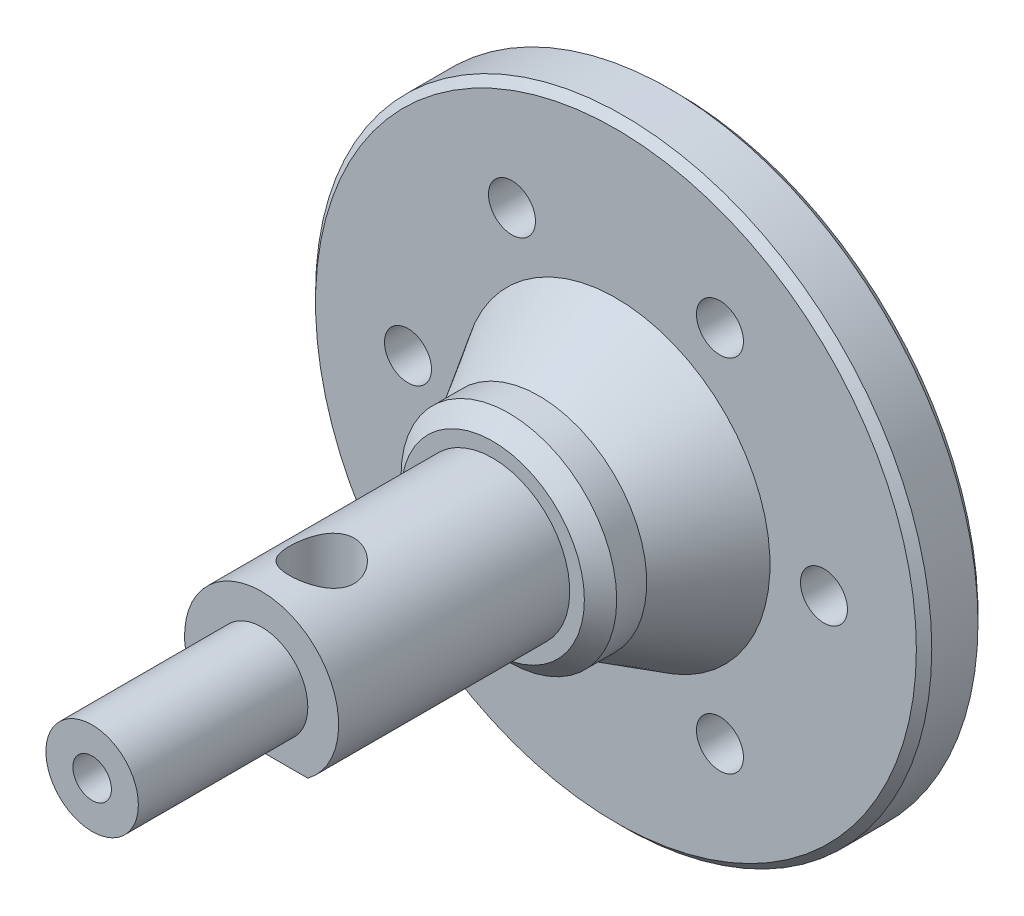
from build123d import *

# Parameters (mm, degrees)
SKETCH_1_R             = 20
EXTRUDE_1_DEPTH        = 5
SKETCH_2_R             = 1.525
CUT_EXTRUDE_1_DEPTH    = 5
SKETCH_3_R             = 7
EXTRUDE_2_DEPTH        = 4
SKETCH_4_R             = 5
EXTRUDE_3_DEPTH        = 15
CHAMFER_2_SIZE         = 1.05
CUT_EXTRUDE_2_DEPTH    = 15
SKETCH_7_R             = 3
EXTRUDE_4_DEPTH        = 10
SKETCH_8_R             = 20
SKETCH_8_R_2           = 7
CUT_EXTRUDE_3_DEPTH    = 1
SKETCH_9_R             = 20
SKETCH_9_R_2           = 1.525
EXTRUDE_5_DEPTH        = 3
SKETCH_10_R            = 20
SKETCH_10_R_2          = 7
CUT_EXTRUDE_4_DEPTH    = 3
SKETCH_11_R            = 3
EXTRUDE_6_DEPTH        = 1
HOLE_WIZARD_M3_1_D     = 2.5
HOLE_WIZARD_M3_1_DEPTH = 5
HOLE_WIZARD_M3_1_TIP   = 0.751075774
CHAMFER_3_SIZE         = 0.5
HOLE_WIZARD_M5_1_D     = 4.2
CHAMFER_4_SIZE         = 1


with BuildPart() as part:
    # 草图1 → 凸台-拉伸1 (new body)
    with BuildSketch(Plane.XY):
        Circle(SKETCH_1_R)
    extrude(amount=EXTRUDE_1_DEPTH)

    # 草图2 → 切除-拉伸1 (cut)
    with BuildSketch(Plane.XY.offset(5)):
        with Locations((13.5, 0)):
            Circle(SKETCH_2_R)
        with Locations((6.75, -11.691342951)):
            Circle(SKETCH_2_R)
        with Locations((-6.75, -11.691342951)):
            Circle(SKETCH_2_R)
        with Locations((-13.5, 0)):
            Circle(SKETCH_2_R)
        with Locations((-6.75, 11.691342951)):
            Circle(SKETCH_2_R)
        with Locations((6.75, 11.691342951)):
            Circle(SKETCH_2_R)
    extrude(amount=-CUT_EXTRUDE_1_DEPTH, mode=Mode.SUBTRACT)

    # 草图3 → 凸台-拉伸2 (add)
    with BuildSketch(Plane.XY.offset(5)):
        Circle(SKETCH_3_R)
    extrude(amount=EXTRUDE_2_DEPTH)

    # 草图4 → 凸台-拉伸3 (add)
    with BuildSketch(Plane.XY.offset(9)):
        Circle(SKETCH_4_R)
    extrude(amount=EXTRUDE_3_DEPTH)

    # 倒角2
    chamfer_2_edges = [part.edges().sort_by_distance(p)[0] for p in [
        (-7, 0, 9),
    ]]
    chamfer(chamfer_2_edges, length=CHAMFER_2_SIZE)

    # 草图6 → 切除-拉伸2 (cut)
    with BuildSketch(Plane.XY.offset(24)):
        with BuildLine():
            Line((-3, -4), (3, -4))
            ThreePointArc((3, -4), (0, -5), (-3, -4))
        make_face()
    extrude(amount=-CUT_EXTRUDE_2_DEPTH, mode=Mode.SUBTRACT)

    # 草图7 → 凸台-拉伸4 (add)
    with BuildSketch(Plane.XY.offset(24)):
        Circle(SKETCH_7_R)
    extrude(amount=EXTRUDE_4_DEPTH)

    # 草图8 → 切除-拉伸3 (cut)
    with BuildSketch(Plane.XY.offset(5)):
        Circle(SKETCH_8_R)
        Circle(SKETCH_8_R_2, mode=Mode.SUBTRACT)
    extrude(amount=-CUT_EXTRUDE_3_DEPTH, mode=Mode.SUBTRACT)

    # 草图9 → 凸台-拉伸5 (add)
    with BuildSketch(Plane(origin=(0, 0, 0), x_dir=(-1, 0, 0), z_dir=(0, 0, -1))):
        Circle(SKETCH_9_R)
        with Locations((6.75, 11.691342951)):
            Circle(SKETCH_9_R_2, mode=Mode.SUBTRACT)
        with Locations((13.5, 0)):
            Circle(SKETCH_9_R_2, mode=Mode.SUBTRACT)
        with Locations((6.75, -11.691342951)):
            Circle(SKETCH_9_R_2, mode=Mode.SUBTRACT)
        with Locations((-6.75, -11.691342951)):
            Circle(SKETCH_9_R_2, mode=Mode.SUBTRACT)
        with Locations((-13.5, 0)):
            Circle(SKETCH_9_R_2, mode=Mode.SUBTRACT)
        with Locations((-6.75, 11.691342951)):
            Circle(SKETCH_9_R_2, mode=Mode.SUBTRACT)
    extrude(amount=EXTRUDE_5_DEPTH)

    # 草图10 → 切除-拉伸4 (cut)
    with BuildSketch(Plane.XY.offset(4)):
        Circle(SKETCH_10_R)
        Circle(SKETCH_10_R_2, mode=Mode.SUBTRACT)
    extrude(amount=-CUT_EXTRUDE_4_DEPTH, mode=Mode.SUBTRACT)

    # 草图11 → 凸台-拉伸6 (add)
    with BuildSketch(Plane.XY.offset(34)):
        Circle(SKETCH_11_R)
    extrude(amount=EXTRUDE_6_DEPTH)

    # M3 螺纹孔1
    with Locations(Plane.XY.offset(35)):
        with Locations((0, 0)):
            Hole(HOLE_WIZARD_M3_1_D / 2, depth=HOLE_WIZARD_M3_1_DEPTH)
            with Locations((0, 0, -(HOLE_WIZARD_M3_1_DEPTH + HOLE_WIZARD_M3_1_TIP / 2))):  # 118° drill point
                Cone(0, HOLE_WIZARD_M3_1_D / 2, HOLE_WIZARD_M3_1_TIP, mode=Mode.SUBTRACT)

    # 倒角3
    chamfer_3_edges = [part.edges().sort_by_distance(p)[0] for p in [
        (-20, 0, 1),
        (20, 0, -3),
    ]]
    chamfer(chamfer_3_edges, length=CHAMFER_3_SIZE)

    # M5 螺纹孔1 (through all)
    with Locations(Plane(origin=(0, -4, 20.1), x_dir=(0, 0, -1), z_dir=(0, -1, 0))):
        with Locations((0, 0)):
            Hole(HOLE_WIZARD_M5_1_D / 2)

    # 倒角4
    chamfer_4_edges = [part.edges().sort_by_distance(p)[0] for p in [
        (-7, 0, 1),
    ]]
    chamfer(chamfer_4_edges, length=CHAMFER_4_SIZE)

    # 草图22 → 旋转2 (revolve)
    with BuildSketch(Plane(origin=(0, 0, 0), x_dir=(1, 0, 0), z_dir=(0, 1, 0))):
        Polygon((6.5, -6.833333333), (10, -1), (6.5, -1), align=None)
    revolve(axis=Axis((0, 0, 0), (0, 0, 1)))


solid = part.part
